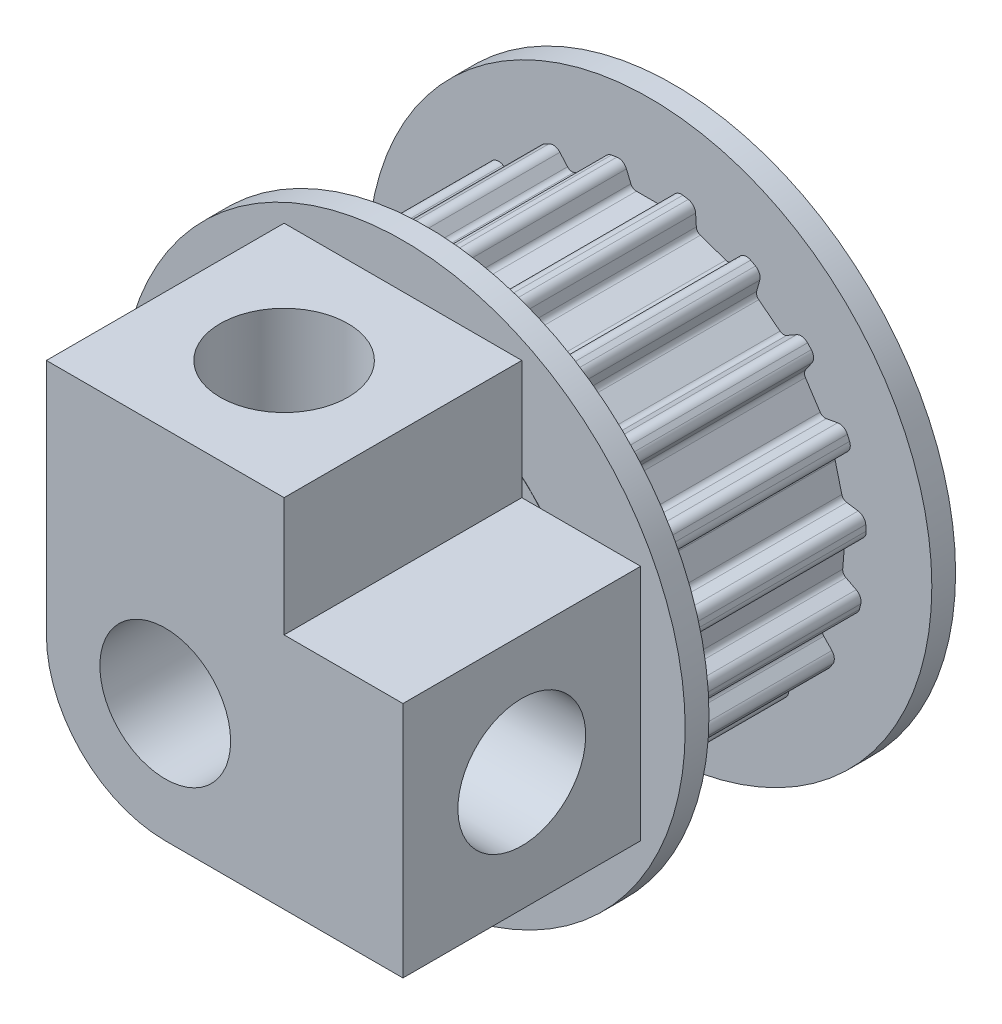
from build123d import *

# Parameters (mm, degrees)
TOOTH_EXTRUDE_START    = -3.75
TOOTH_EXTRUDE_DEPTH    = 7.5
TOOTH_PATTERN_19_COUNT = 19
SKETCH3_R              = 2.2
CUT_EXTRUDE2_DEPTH     = 10.12
SKETCH6_R              = 2.2
BOSS_EXTRUDE1_DEPTH    = 8
SKETCH7_R              = 2.15
CUT_EXTRUDE3_DEPTH     = 8
SKETCH8_R              = 2.15
CUT_EXTRUDE4_DEPTH     = 8


with BuildPart() as part:
    # GearBelt-BaseSketch → T 2_5 Form SE DIN 7721_ 6mm Belt Width (revolve)
    with BuildSketch(Plane(origin=(0, 0, 0), x_dir=(0, 0, -1), z_dir=(1, 0, 0))):
        Polygon((-4.56, 0), (4.56, 0), (4.56, 6.099999905), (4.55, 6.099999905), (4.55, 7.330870102), (4.55, 9.49), (3.75, 9.49), (3.75, 7.49), (3.75, 7.3), (-3.75, 7.3), (-3.75, 7.49), (-3.75, 9.49), (-4.55, 9.49), (-4.55, 7.330870102), (-4.55, 6.099999905), (-4.56, 6.099999905), align=None)
    revolve(axis=Axis((0, 0, 6.84), (0, 0, -1)))

    # Tooth-Sketch → Tooth-Extrude (cut)
    with BuildSketch(Plane.XY.offset(TOOTH_EXTRUDE_START)):
        with BuildLine():
            Line((-0.453445584, 6.55), (0.453445584, 6.55))
            ThreePointArc((0.453445584, 6.55), (0.564559632, 6.583706078), (0.638221493, 6.673463315))
            Line((0.638221493, 6.673463315), (0.787310301, 7.033395539))
            ThreePointArc((0.787310301, 7.033395539), (0.917309737, 7.18001475), (1.110094497, 7.215101538))
            Line((1.110094497, 7.215101538), (1.110094497, 9.755101538))
            Line((1.110094497, 9.755101538), (-1.110094497, 9.755101538))
            Line((-1.110094497, 9.755101538), (-1.110094497, 7.215101538))
            ThreePointArc((-1.110094497, 7.215101538), (-0.917309737, 7.18001475), (-0.787310301, 7.033395539))
            Line((-0.787310301, 7.033395539), (-0.638221493, 6.673463315))
            ThreePointArc((-0.638221493, 6.673463315), (-0.564559632, 6.583706078), (-0.453445584, 6.55))
        make_face()
    tooth_extrude = extrude(amount=TOOTH_EXTRUDE_DEPTH, mode=Mode.SUBTRACT)

    # Tooth Pattern_ 19: Tooth-Extrude ×19 about axis
    tooth_pattern_19_axis = Axis((0, 0, 0), (0, 0, 1))
    for i in range(1, TOOTH_PATTERN_19_COUNT):
        add(tooth_extrude.rotate(tooth_pattern_19_axis, i * 360 / TOOTH_PATTERN_19_COUNT), mode=Mode.SUBTRACT)

    # Sketch3 → Cut-Extrude2 (cut, through all)
    with BuildSketch(Plane.XY.offset(4.56)):
        Circle(SKETCH3_R)
    extrude(amount=-CUT_EXTRUDE2_DEPTH, mode=Mode.SUBTRACT)

    # Sketch6 → Boss-Extrude1 (add)
    with BuildSketch(Plane.XY.offset(4.56)):
        with BuildLine():
            Line((-4, 0), (-4, 8))
            Line((-4, 8), (4, 8))
            Line((4, 8), (4, 4))
            Line((4, 4), (8, 4))
            Line((8, 4), (8, -4))
            Line((8, -4), (0, -4))
            ThreePointArc((0, -4), (-2.828427125, -2.828427125), (-4, 0))
        make_face()
        Circle(SKETCH6_R, mode=Mode.SUBTRACT)
    extrude(amount=BOSS_EXTRUDE1_DEPTH)

    # Sketch7 → Cut-Extrude3 (cut)
    with BuildSketch(Plane(origin=(0, 8, 0), x_dir=(1, 0, 0), z_dir=(0, 1, 0))):
        with Locations((0, -8.56)):
            Circle(SKETCH7_R)
    extrude(amount=-CUT_EXTRUDE3_DEPTH, mode=Mode.SUBTRACT)

    # Sketch8 → Cut-Extrude4 (cut)
    with BuildSketch(Plane(origin=(8, 0, 0), x_dir=(0, 0, -1), z_dir=(1, 0, 0))):
        with Locations((-8.56, 0)):
            Circle(SKETCH8_R)
    extrude(amount=-CUT_EXTRUDE4_DEPTH, mode=Mode.SUBTRACT)


solid = part.part
